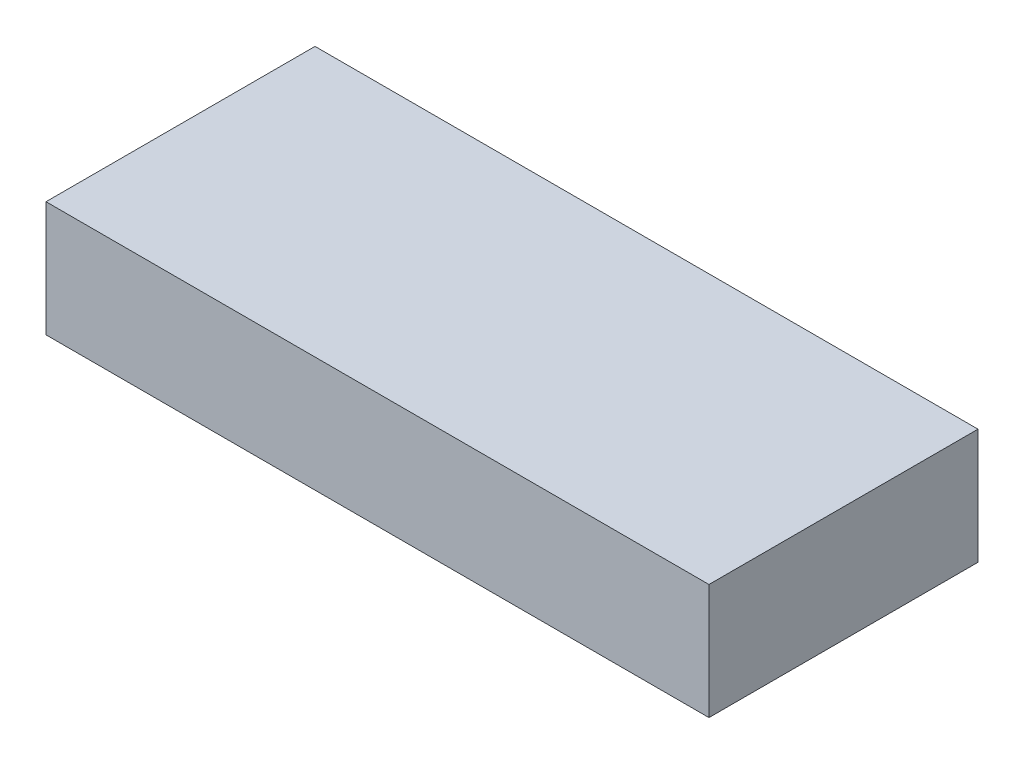
from build123d import *

# Parameters (mm, degrees)
SKETCH1_W           = 219.075
SKETCH1_H           = 88.9
BOSS_EXTRUDE1_DEPTH = 38.1


with BuildPart() as part:
    # Sketch1 → Boss-Extrude1 (new body)
    with BuildSketch(Plane(origin=(0, 0, 0), x_dir=(1, 0, 0), z_dir=(0, 1, 0))):
        with Locations((109.5375, 44.45)):
            Rectangle(SKETCH1_W, SKETCH1_H)
    extrude(amount=BOSS_EXTRUDE1_DEPTH)


solid = part.part
